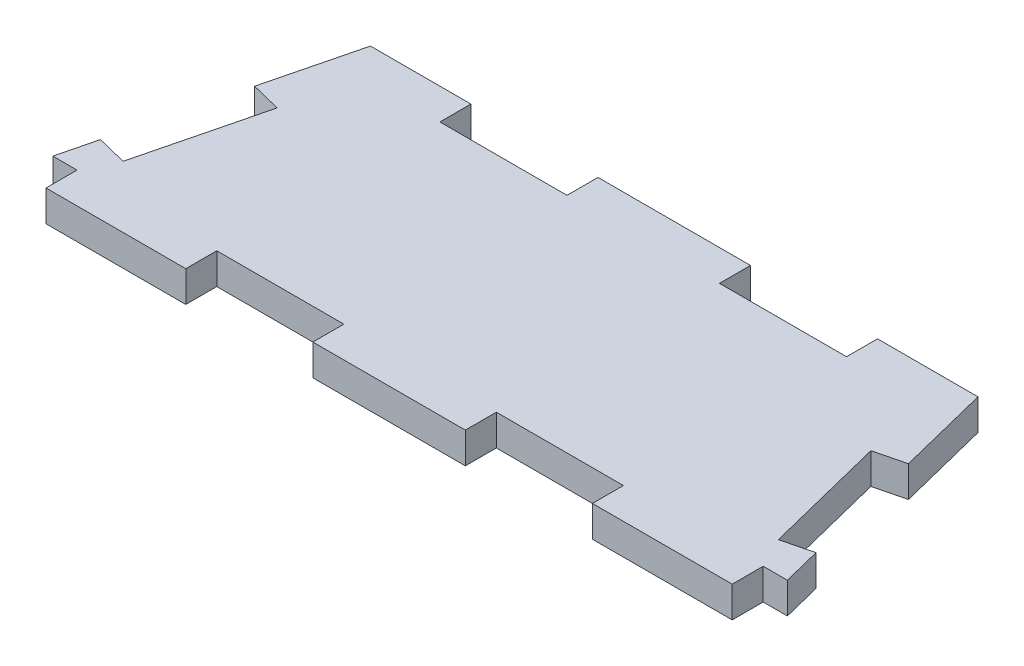
from build123d import *

# Parameters (mm, degrees)
SALIENTE_EXTRUIR3_DEPTH = 2.44


with BuildPart() as part:
    # Croquis1 → Saliente-Extruir3 (new body)
    with BuildSketch(Plane(origin=(0, 0, 0), x_dir=(1, 0, 0), z_dir=(0, 1, 0))):
        Polygon((-27, 0), (-16, 0), (-16, 2.44), (-6, 2.44), (-6, 0), (6, 0), (6, 2.44), (16, 2.44), (16, 0), (27, 0), (27, 2.44), (28.905094432, 2.44), (28.154469575, 5.442499426), (25.787321875, 4.850712501), (23.361965624, 14.552137502), (25.729113325, 15.143924427), (23.905094432, 22.44), (16, 22.44), (16, 20), (6, 20), (6, 22.44), (-6, 22.44), (-6, 20), (-16, 20), (-16, 22.44), (-23.905094432, 22.44), (-25.729113325, 15.143924427), (-23.361965624, 14.552137502), (-25.787321875, 4.850712501), (-28.154469575, 5.442499426), (-28.905094432, 2.44), (-27, 2.44), align=None)
    extrude(amount=SALIENTE_EXTRUIR3_DEPTH)


solid = part.part
